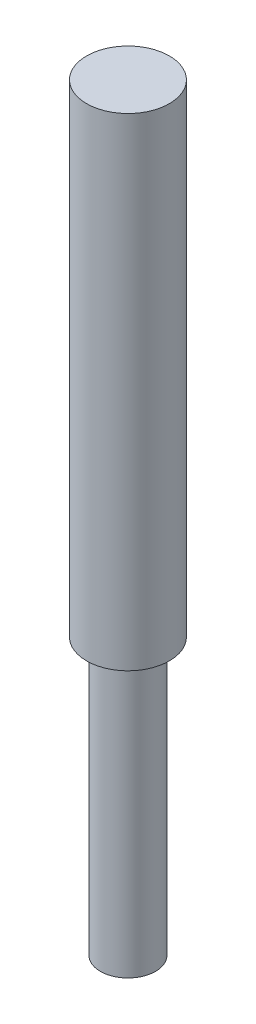
from build123d import *

# Parameters (mm, degrees)
SKETCH1_R           = 3
BOSS_EXTRUDE1_DEPTH = 35
SKETCH1_3_R         = 2
BOSS_EXTRUDE2_DEPTH = 20


with BuildPart() as part:
    # Sketch1 → Boss-Extrude1 (new body)
    with BuildSketch(Plane(origin=(0, 0, 0), x_dir=(1, 0, 0), z_dir=(0, 1, 0))):
        Circle(SKETCH1_R)
    extrude(amount=BOSS_EXTRUDE1_DEPTH)

    # Sketch1_3 → Boss-Extrude2 (add)
    with BuildSketch(Plane(origin=(0, 0, 0), x_dir=(1, 0, 0), z_dir=(0, 1, 0))):
        Circle(SKETCH1_3_R)
    extrude(amount=-BOSS_EXTRUDE2_DEPTH)


solid = part.part
